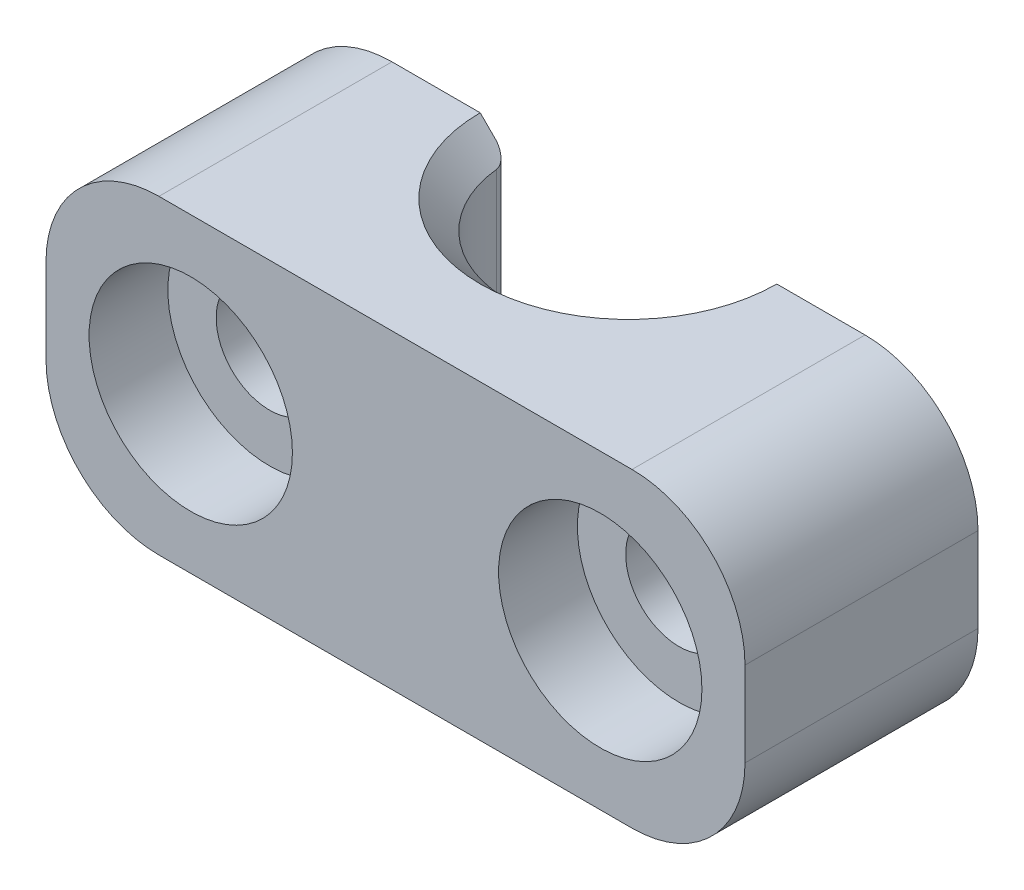
from build123d import *

# Parameters (mm, degrees)
CROQUIS1_W                                           = 24.75
CROQUIS1_H                                           = 11
SALIENTE_EXTRUIR1_DEPTH                              = 8.25
REFRENTADO_PARA_TORNILLO_CON_CABEZA_HEXA_D           = 3.78
REFRENTADO_PARA_TORNILLO_CON_CABEZA_HEXA_DEPTH       = 8.25
REFRENTADO_PARA_TORNILLO_CON_CABEZA_HEXA_CBORE_D     = 7.2
REFRENTADO_PARA_TORNILLO_CON_CABEZA_HEXA_CBORE_DEPTH = 2.79
DI_METRO_DE_TALADRO_8_5_8_5_1_D                      = 8.5
DI_METRO_DE_TALADRO_8_5_8_5_1_DEPTH                  = 11
CHAFL_N1_SIZE                                        = 1
REDONDEO1_R                                          = 0.5
REDONDEO2_R                                          = 4


with BuildPart() as part:
    # Croquis1 → Saliente-Extruir1 (new body)
    with BuildSketch(Plane(origin=(0, 0, 0), x_dir=(-1, 0, 0), z_dir=(0, 0, -1))):
        Rectangle(CROQUIS1_W, CROQUIS1_H)
    extrude(amount=-SALIENTE_EXTRUIR1_DEPTH)

    # Refrentado para tornillo con cabeza hexagonal de M3.51
    with Locations(Plane.XY.offset(8.25)):
        with Locations((-7.25, 0), (7.25, 0)):
            CounterBoreHole(REFRENTADO_PARA_TORNILLO_CON_CABEZA_HEXA_D / 2, REFRENTADO_PARA_TORNILLO_CON_CABEZA_HEXA_CBORE_D / 2, REFRENTADO_PARA_TORNILLO_CON_CABEZA_HEXA_CBORE_DEPTH, depth=REFRENTADO_PARA_TORNILLO_CON_CABEZA_HEXA_DEPTH)

    # Diámetro de taladro Ø8.5 (8.5)1
    with Locations(Plane(origin=(0, 5.5, 0), x_dir=(1, 0, 0), z_dir=(0, 1, 0))):
        with Locations((0, 0)):
            Hole(DI_METRO_DE_TALADRO_8_5_8_5_1_D / 2, depth=DI_METRO_DE_TALADRO_8_5_8_5_1_DEPTH)

    # Chaflán1
    chafl_n1_edges = [part.edges().sort_by_distance(p)[0] for p in [
        (0, 5.5, 4.25),
        (0, -5.5, 4.25),
    ]]
    chamfer(chafl_n1_edges, length=CHAFL_N1_SIZE)

    # Redondeo1
    redondeo1_edges = [part.edges().sort_by_distance(p)[0] for p in [
        (4.25, 0, 0),
        (-4.25, 0, 0),
    ]]
    fillet(redondeo1_edges, radius=REDONDEO1_R)

    # Redondeo2
    redondeo2_edges = [part.edges().sort_by_distance(p)[0] for p in [
        (-12.375, 5.5, 4.125),
        (-12.375, -5.5, 4.125),
        (12.375, -5.5, 4.125),
        (12.375, 5.5, 4.125),
    ]]
    fillet(redondeo2_edges, radius=REDONDEO2_R)


solid = part.part
